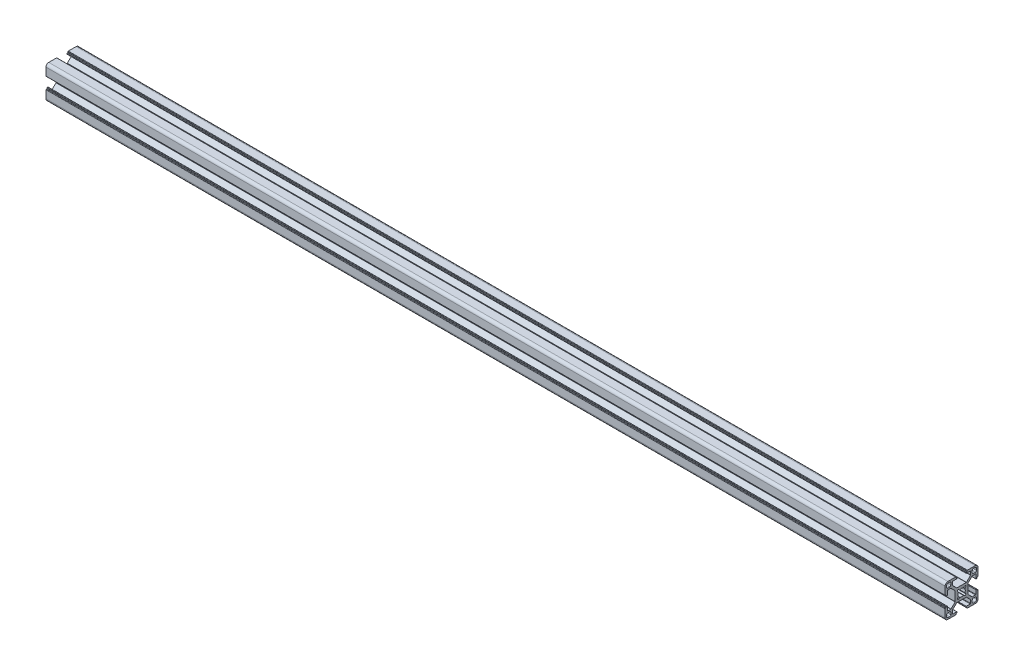
from build123d import *

# Parameters (mm, degrees)
BOSS_EXTRUDE1_DEPTH = 820


with BuildPart() as part:
    # Sketch1 → Boss-Extrude1 (new body)
    with BuildSketch(Plane(origin=(0, 0, 0), x_dir=(0, 0, -1), z_dir=(1, 0, 0))):
        with BuildLine():
            Line((-8.25, 9.788477631), (-8.25, 12.7))
            ThreePointArc((-8.25, 12.7), (-8.162132034, 12.912132034), (-7.95, 13))
            Line((-7.95, 13), (-4.4, 13))
            ThreePointArc((-4.4, 13), (-4.187867966, 13.087867966), (-4.1, 13.3))
            Line((-4.1, 13.3), (-4.1, 13.7))
            ThreePointArc((-4.1, 13.7), (-4.187867966, 13.912132034), (-4.4, 14))
            Line((-4.4, 14), (-4.8, 14))
            ThreePointArc((-4.8, 14), (-5.012132034, 14.087867966), (-5.1, 14.3))
            Line((-5.1, 14.3), (-5.1, 14.7))
            ThreePointArc((-5.1, 14.7), (-5.187867966, 14.912132034), (-5.4, 15))
            Line((-5.4, 15), (-12.5, 15))
            ThreePointArc((-12.5, 15), (-14.267766953, 14.267766953), (-15, 12.5))
            Line((-15, 12.5), (-15, 5.4))
            ThreePointArc((-15, 5.4), (-14.912132034, 5.187867966), (-14.7, 5.1))
            Line((-14.7, 5.1), (-14.3, 5.1))
            ThreePointArc((-14.3, 5.1), (-14.087867966, 5.012132034), (-14, 4.8))
            Line((-14, 4.8), (-14, 4.4))
            ThreePointArc((-14, 4.4), (-13.912132034, 4.187867966), (-13.7, 4.1))
            Line((-13.7, 4.1), (-13.3, 4.1))
            ThreePointArc((-13.3, 4.1), (-13.087867966, 4.187867966), (-13, 4.4))
            Line((-13, 4.4), (-13, 7.95))
            ThreePointArc((-13, 7.95), (-12.912132034, 8.162132034), (-12.7, 8.25))
            Line((-12.7, 8.25), (-9.788477631, 8.25))
            ThreePointArc((-9.788477631, 8.25), (-9.673672601, 8.22716386), (-9.576345597, 8.162132034))
            Line((-9.576345597, 8.162132034), (-5.887867966, 4.473654403))
            ThreePointArc((-5.887867966, 4.473654403), (-5.82283614, 4.376327399), (-5.8, 4.261522369))
            Line((-5.8, 4.261522369), (-5.8, -4.261522369))
            ThreePointArc((-5.8, -4.261522369), (-5.82283614, -4.376327399), (-5.887867966, -4.473654403))
            Line((-5.887867966, -4.473654403), (-9.576345597, -8.162132034))
            ThreePointArc((-9.576345597, -8.162132034), (-9.673672601, -8.22716386), (-9.788477631, -8.25))
            Line((-9.788477631, -8.25), (-12.7, -8.25))
            ThreePointArc((-12.7, -8.25), (-12.912132034, -8.162132034), (-13, -7.95))
            Line((-13, -7.95), (-13, -4.4))
            ThreePointArc((-13, -4.4), (-13.087867966, -4.187867966), (-13.3, -4.1))
            Line((-13.3, -4.1), (-13.7, -4.1))
            ThreePointArc((-13.7, -4.1), (-13.912132034, -4.187867966), (-14, -4.4))
            Line((-14, -4.4), (-14, -4.8))
            ThreePointArc((-14, -4.8), (-14.087867966, -5.012132034), (-14.3, -5.1))
            Line((-14.3, -5.1), (-14.7, -5.1))
            ThreePointArc((-14.7, -5.1), (-14.912132034, -5.187867966), (-15, -5.4))
            Line((-15, -5.4), (-15, -12.5))
            ThreePointArc((-15, -12.5), (-14.267766953, -14.267766953), (-12.5, -15))
            Line((-12.5, -15), (-5.4, -15))
            ThreePointArc((-5.4, -15), (-5.187867966, -14.912132034), (-5.1, -14.7))
            Line((-5.1, -14.7), (-5.1, -14.3))
            ThreePointArc((-5.1, -14.3), (-5.012132034, -14.087867966), (-4.8, -14))
            Line((-4.8, -14), (-4.4, -14))
            ThreePointArc((-4.4, -14), (-4.187867966, -13.912132034), (-4.1, -13.7))
            Line((-4.1, -13.7), (-4.1, -13.3))
            ThreePointArc((-4.1, -13.3), (-4.187867966, -13.087867966), (-4.4, -13))
            Line((-4.4, -13), (-7.95, -13))
            ThreePointArc((-7.95, -13), (-8.162132034, -12.912132034), (-8.25, -12.7))
            Line((-8.25, -12.7), (-8.25, -9.788477631))
            ThreePointArc((-8.25, -9.788477631), (-8.22716386, -9.673672601), (-8.162132034, -9.576345597))
            Line((-8.162132034, -9.576345597), (-4.473654403, -5.887867966))
            ThreePointArc((-4.473654403, -5.887867966), (-4.376327399, -5.82283614), (-4.261522369, -5.8))
            Line((-4.261522369, -5.8), (4.261522369, -5.8))
            ThreePointArc((4.261522369, -5.8), (4.376327399, -5.82283614), (4.473654403, -5.887867966))
            Line((4.473654403, -5.887867966), (8.162132034, -9.576345597))
            ThreePointArc((8.162132034, -9.576345597), (8.22716386, -9.673672601), (8.25, -9.788477631))
            Line((8.25, -9.788477631), (8.25, -12.7))
            ThreePointArc((8.25, -12.7), (8.162132034, -12.912132034), (7.95, -13))
            Line((7.95, -13), (4.4, -13))
            ThreePointArc((4.4, -13), (4.187867966, -13.087867966), (4.1, -13.3))
            Line((4.1, -13.3), (4.1, -13.7))
            ThreePointArc((4.1, -13.7), (4.187867966, -13.912132034), (4.4, -14))
            Line((4.4, -14), (4.8, -14))
            ThreePointArc((4.8, -14), (5.012132034, -14.087867966), (5.1, -14.3))
            Line((5.1, -14.3), (5.1, -14.7))
            ThreePointArc((5.1, -14.7), (5.187867966, -14.912132034), (5.4, -15))
            Line((5.4, -15), (12.5, -15))
            ThreePointArc((12.5, -15), (14.267766953, -14.267766953), (15, -12.5))
            Line((15, -12.5), (15, -5.4))
            ThreePointArc((15, -5.4), (14.912132034, -5.187867966), (14.7, -5.1))
            Line((14.7, -5.1), (14.3, -5.1))
            ThreePointArc((14.3, -5.1), (14.087867966, -5.012132034), (14, -4.8))
            Line((14, -4.8), (14, -4.4))
            ThreePointArc((14, -4.4), (13.912132034, -4.187867966), (13.7, -4.1))
            Line((13.7, -4.1), (13.3, -4.1))
            ThreePointArc((13.3, -4.1), (13.087867966, -4.187867966), (13, -4.4))
            Line((13, -4.4), (13, -7.95))
            ThreePointArc((13, -7.95), (12.912132034, -8.162132034), (12.7, -8.25))
            Line((12.7, -8.25), (9.788477631, -8.25))
            ThreePointArc((9.788477631, -8.25), (9.673672601, -8.22716386), (9.576345597, -8.162132034))
            Line((9.576345597, -8.162132034), (5.887867966, -4.473654403))
            ThreePointArc((5.887867966, -4.473654403), (5.82283614, -4.376327399), (5.8, -4.261522369))
            Line((5.8, -4.261522369), (5.8, 4.261522369))
            ThreePointArc((5.8, 4.261522369), (5.82283614, 4.376327399), (5.887867966, 4.473654403))
            Line((5.887867966, 4.473654403), (9.576345597, 8.162132034))
            ThreePointArc((9.576345597, 8.162132034), (9.673672601, 8.22716386), (9.788477631, 8.25))
            Line((9.788477631, 8.25), (12.7, 8.25))
            ThreePointArc((12.7, 8.25), (12.912132034, 8.162132034), (13, 7.95))
            Line((13, 7.95), (13, 4.4))
            ThreePointArc((13, 4.4), (13.087867966, 4.187867966), (13.3, 4.1))
            Line((13.3, 4.1), (13.7, 4.1))
            ThreePointArc((13.7, 4.1), (13.912132034, 4.187867966), (14, 4.4))
            Line((14, 4.4), (14, 4.8))
            ThreePointArc((14, 4.8), (14.087867966, 5.012132034), (14.3, 5.1))
            Line((14.3, 5.1), (14.7, 5.1))
            ThreePointArc((14.7, 5.1), (14.912132034, 5.187867966), (15, 5.4))
            Line((15, 5.4), (15, 12.5))
            ThreePointArc((15, 12.5), (14.267766953, 14.267766953), (12.5, 15))
            Line((12.5, 15), (5.4, 15))
            ThreePointArc((5.4, 15), (5.187867966, 14.912132034), (5.1, 14.7))
            Line((5.1, 14.7), (5.1, 14.3))
            ThreePointArc((5.1, 14.3), (5.012132034, 14.087867966), (4.8, 14))
            Line((4.8, 14), (4.4, 14))
            ThreePointArc((4.4, 14), (4.187867966, 13.912132034), (4.1, 13.7))
            Line((4.1, 13.7), (4.1, 13.3))
            ThreePointArc((4.1, 13.3), (4.187867966, 13.087867966), (4.4, 13))
            Line((4.4, 13), (7.95, 13))
            ThreePointArc((7.95, 13), (8.162132034, 12.912132034), (8.25, 12.7))
            Line((8.25, 12.7), (8.25, 9.788477631))
            ThreePointArc((8.25, 9.788477631), (8.22716386, 9.673672601), (8.162132034, 9.576345597))
            Line((8.162132034, 9.576345597), (4.473654403, 5.887867966))
            ThreePointArc((4.473654403, 5.887867966), (4.376327399, 5.82283614), (4.261522369, 5.8))
            Line((4.261522369, 5.8), (-4.261522369, 5.8))
            ThreePointArc((-4.261522369, 5.8), (-4.376327399, 5.82283614), (-4.473654403, 5.887867966))
            Line((-4.473654403, 5.887867966), (-8.162132034, 9.576345597))
            ThreePointArc((-8.162132034, 9.576345597), (-8.22716386, 9.673672601), (-8.25, 9.788477631))
        make_face()
        with BuildLine():
            Line((3.05514787, -1.904659815), (3.741964502, -2.698343541))
            ThreePointArc((3.741964502, -2.698343541), (3.70396732, -3.720635173), (2.68151539, -3.75404201))
            Line((2.68151539, -3.75404201), (1.890923385, -3.06366876))
            ThreePointArc((1.890923385, -3.06366876), (1.729867527, -2.991839768), (1.556279141, -3.022911715))
            ThreePointArc((1.556279141, -3.022911715), (0, -3.4), (-1.55627914, -3.022911715))
            ThreePointArc((-1.55627914, -3.022911715), (-1.729867526, -2.991839768), (-1.890923385, -3.06366876))
            Line((-1.890923385, -3.06366876), (-2.68151539, -3.75404201))
            ThreePointArc((-2.68151539, -3.75404201), (-3.70396732, -3.720635173), (-3.741964502, -2.698343541))
            Line((-3.741964502, -2.698343541), (-3.05514787, -1.904659815))
            ThreePointArc((-3.05514787, -1.904659815), (-2.984042722, -1.743283077), (-3.015893746, -1.56983595))
            ThreePointArc((-3.015893746, -1.56983595), (-3.4, 0), (-3.015893746, 1.56983595))
            ThreePointArc((-3.015893746, 1.56983595), (-2.984042722, 1.743283077), (-3.05514787, 1.904659815))
            Line((-3.05514787, 1.904659815), (-3.741964502, 2.698343541))
            ThreePointArc((-3.741964502, 2.698343541), (-3.70396732, 3.720635173), (-2.68151539, 3.75404201))
            Line((-2.68151539, 3.75404201), (-1.890923385, 3.06366876))
            ThreePointArc((-1.890923385, 3.06366876), (-1.729867526, 2.991839768), (-1.55627914, 3.022911715))
            ThreePointArc((-1.55627914, 3.022911715), (0, 3.4), (1.556279141, 3.022911715))
            ThreePointArc((1.556279141, 3.022911715), (1.729867527, 2.991839768), (1.890923385, 3.06366876))
            Line((1.890923385, 3.06366876), (2.68151539, 3.75404201))
            ThreePointArc((2.68151539, 3.75404201), (3.70396732, 3.720635173), (3.741964502, 2.698343541))
            Line((3.741964502, 2.698343541), (3.05514787, 1.904659815))
            ThreePointArc((3.05514787, 1.904659815), (2.984042722, 1.743283077), (3.015893747, 1.56983595))
            ThreePointArc((3.015893747, 1.56983595), (3.4, 0), (3.015893747, -1.56983595))
            ThreePointArc((3.015893747, -1.56983595), (2.984042722, -1.743283077), (3.05514787, -1.904659815))
        make_face(mode=Mode.SUBTRACT)
        with BuildLine():
            Line((10.75, -9.75), (12.65, -9.75))
            ThreePointArc((12.65, -9.75), (13.357106781, -10.042893219), (13.65, -10.75))
            Line((13.65, -10.75), (13.65, -12.15))
            ThreePointArc((13.65, -12.15), (13.210660172, -13.210660172), (12.15, -13.65))
            Line((12.15, -13.65), (10.75, -13.65))
            ThreePointArc((10.75, -13.65), (10.042893219, -13.357106781), (9.75, -12.65))
            Line((9.75, -12.65), (9.75, -10.75))
            ThreePointArc((9.75, -10.75), (10.042893219, -10.042893219), (10.75, -9.75))
        make_face(mode=Mode.SUBTRACT)
        with BuildLine():
            Line((-10.75, 9.75), (-12.65, 9.75))
            ThreePointArc((-12.65, 9.75), (-13.357106781, 10.042893219), (-13.65, 10.75))
            Line((-13.65, 10.75), (-13.65, 12.15))
            ThreePointArc((-13.65, 12.15), (-13.210660172, 13.210660172), (-12.15, 13.65))
            Line((-12.15, 13.65), (-10.75, 13.65))
            ThreePointArc((-10.75, 13.65), (-10.042893219, 13.357106781), (-9.75, 12.65))
            Line((-9.75, 12.65), (-9.75, 10.75))
            ThreePointArc((-9.75, 10.75), (-10.042893219, 10.042893219), (-10.75, 9.75))
        make_face(mode=Mode.SUBTRACT)
        with BuildLine():
            Line((9.75, 10.75), (9.75, 12.65))
            ThreePointArc((9.75, 12.65), (10.042893219, 13.357106781), (10.75, 13.65))
            Line((10.75, 13.65), (12.15, 13.65))
            ThreePointArc((12.15, 13.65), (13.210660172, 13.210660172), (13.65, 12.15))
            Line((13.65, 12.15), (13.65, 10.75))
            ThreePointArc((13.65, 10.75), (13.357106781, 10.042893219), (12.65, 9.75))
            Line((12.65, 9.75), (10.75, 9.75))
            ThreePointArc((10.75, 9.75), (10.042893219, 10.042893219), (9.75, 10.75))
        make_face(mode=Mode.SUBTRACT)
        with BuildLine():
            Line((-9.75, -10.75), (-9.75, -12.65))
            ThreePointArc((-9.75, -12.65), (-10.042893219, -13.357106781), (-10.75, -13.65))
            Line((-10.75, -13.65), (-12.15, -13.65))
            ThreePointArc((-12.15, -13.65), (-13.210660172, -13.210660172), (-13.65, -12.15))
            Line((-13.65, -12.15), (-13.65, -10.75))
            ThreePointArc((-13.65, -10.75), (-13.357106781, -10.042893219), (-12.65, -9.75))
            Line((-12.65, -9.75), (-10.75, -9.75))
            ThreePointArc((-10.75, -9.75), (-10.042893219, -10.042893219), (-9.75, -10.75))
        make_face(mode=Mode.SUBTRACT)
    extrude(amount=BOSS_EXTRUDE1_DEPTH)


solid = part.part
